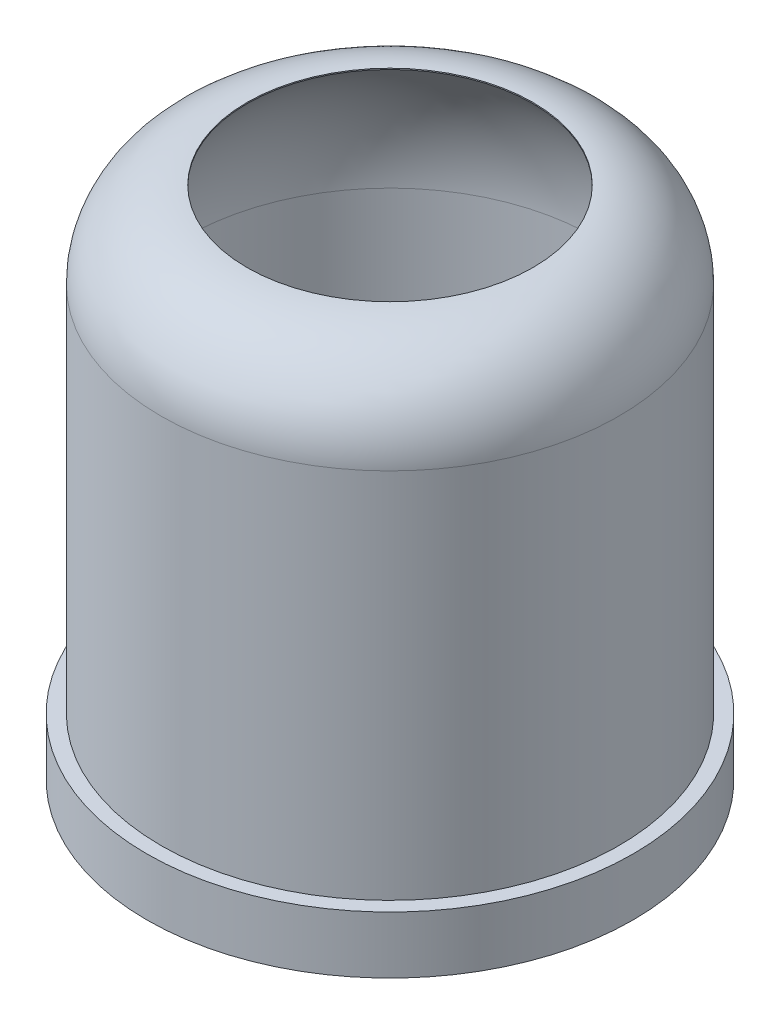
from build123d import *


with BuildPart() as part:
    # Sketch1 → Revolve1 (revolve)
    with BuildSketch(Plane.XY, mode=Mode.PRIVATE) as revolve1_sk:
        with BuildLine():
            Line((-3.125, -4.5), (-4.25, -4.5))
            Line((-4.25, -4.5), (-4.25, -3.5))
            Line((-4.25, -3.5), (-4, -3.5))
            Line((-4, -3.5), (-4, 3))
            ThreePointArc((-4, 3), (-3.560660172, 4.060660172), (-2.5, 4.5))
            Line((-2.5, 4.5), (-2.5, 4.480508756))
            ThreePointArc((-2.5, 4.480508756), (-3.295309166, 3.31120435), (-3.575, 1.925))
            Line((-3.575, 1.925), (-3.575, -2.763624465))
            ThreePointArc((-3.575, -2.763624465), (-3.4606719, -3.66049402), (-3.125, -4.5))
        make_face()
    revolve(revolve1_sk.sketch.rotate(Axis((0, 4.5, 0), (0, -1, 0)), 270), axis=Axis((0, 4.5, 0), (0, -1, 0)))  # turned: the seam where the file's is


solid = part.part
